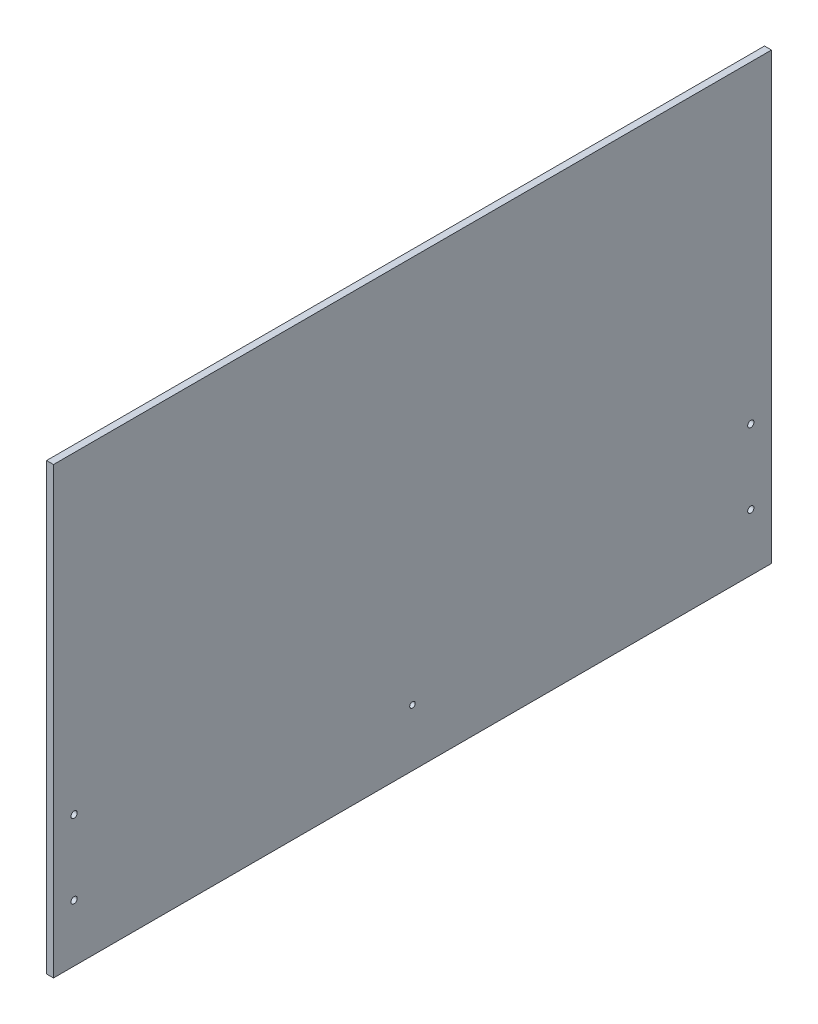
from build123d import *

# Parameters (mm, degrees)
SKETCH1_W                 = 492.125
SKETCH1_H                 = 304.8
BOSS_EXTRUDE1_DEPTH       = 4.7625
CUT_EXTRUDE1_REACH        = 6.763
BOSS_EXTRUDE2_REACH       = 494.125
SKETCH3_W                 = 4.7625
SKETCH3_H                 = 304.8
F_8_CLEARANCE_HOLE1_D     = 4.3053
F_8_CLEARANCE_HOLE1_DEPTH = 74.422
F_8_CLEARANCE_HOLE1_TIP   = 1.293442612
F_6_CLEARANCE_HOLE1_D     = 3.7973
F_6_CLEARANCE_HOLE1_DEPTH = 25.4
F_6_CLEARANCE_HOLE1_TIP   = 1.140824014


with BuildPart() as part:
    # Sketch1 → Boss-Extrude1 (new body)
    with BuildSketch(Plane(origin=(0, 0, 0), x_dir=(0, 0, -1), z_dir=(1, 0, 0))):
        Rectangle(SKETCH1_W, SKETCH1_H)
    extrude(amount=BOSS_EXTRUDE1_DEPTH)

    # Sketch2 → Cut-Extrude1 (cut, up to next)
    with BuildSketch(Plane(origin=(4.7625, 0, 0), x_dir=(0, 0, -1), z_dir=(1, 0, 0)), mode=Mode.PRIVATE) as cut_extrude1_sk1:
        Polygon((-24.852813742, -60), (24.852813742, -60), (42.426406871, -42.426406871), (60, -24.852813742), (60, 24.852813742), (24.852813742, 60), (-24.852813742, 60), (-60, 24.852813742), (-60, -24.852813742), align=None)
    cut_extrude1_tool1 = extrude(cut_extrude1_sk1.sketch, amount=-CUT_EXTRUDE1_REACH, mode=Mode.PRIVATE) & part.part
    add(cut_extrude1_tool1.solids().sort_by_distance((4.7625, 0, 0))[0], mode=Mode.SUBTRACT)

    # Sketch3 → Boss-Extrude2 (add, up to next)
    with BuildSketch(Plane.XY.offset(246.0625), mode=Mode.PRIVATE) as boss_extrude2_sk1:
        with Locations((2.38125, 0)):
            Rectangle(SKETCH3_W, SKETCH3_H)
    boss_extrude2_tool1 = extrude(boss_extrude2_sk1.sketch, amount=-BOSS_EXTRUDE2_REACH, mode=Mode.PRIVATE) - part.part
    add(boss_extrude2_tool1.solids().sort_by_distance((2.38125, 0, 246.0625))[0])

    # #8 Clearance Hole1
    with Locations(Plane(origin=(4.7625, 0, 0), x_dir=(0, 0, -1), z_dir=(1, 0, 0))):
        with Locations((-231.93375, -113.284), (-231.93375, -62.484), (231.93375, -62.484), (231.93375, -113.284)):
            Hole(F_8_CLEARANCE_HOLE1_D / 2, depth=F_8_CLEARANCE_HOLE1_DEPTH)
            with Locations((0, 0, -(F_8_CLEARANCE_HOLE1_DEPTH + F_8_CLEARANCE_HOLE1_TIP / 2))):  # 118° drill point
                Cone(0, F_8_CLEARANCE_HOLE1_D / 2, F_8_CLEARANCE_HOLE1_TIP, mode=Mode.SUBTRACT)

    # #6 Clearance Hole1
    with Locations(Plane(origin=(4.7625, 0, 0), x_dir=(0, 0, -1), z_dir=(1, 0, 0))):
        with Locations((0, -113.284)):
            Hole(F_6_CLEARANCE_HOLE1_D / 2, depth=F_6_CLEARANCE_HOLE1_DEPTH)
            with Locations((0, 0, -(F_6_CLEARANCE_HOLE1_DEPTH + F_6_CLEARANCE_HOLE1_TIP / 2))):  # 118° drill point
                Cone(0, F_6_CLEARANCE_HOLE1_D / 2, F_6_CLEARANCE_HOLE1_TIP, mode=Mode.SUBTRACT)


solid = part.part
